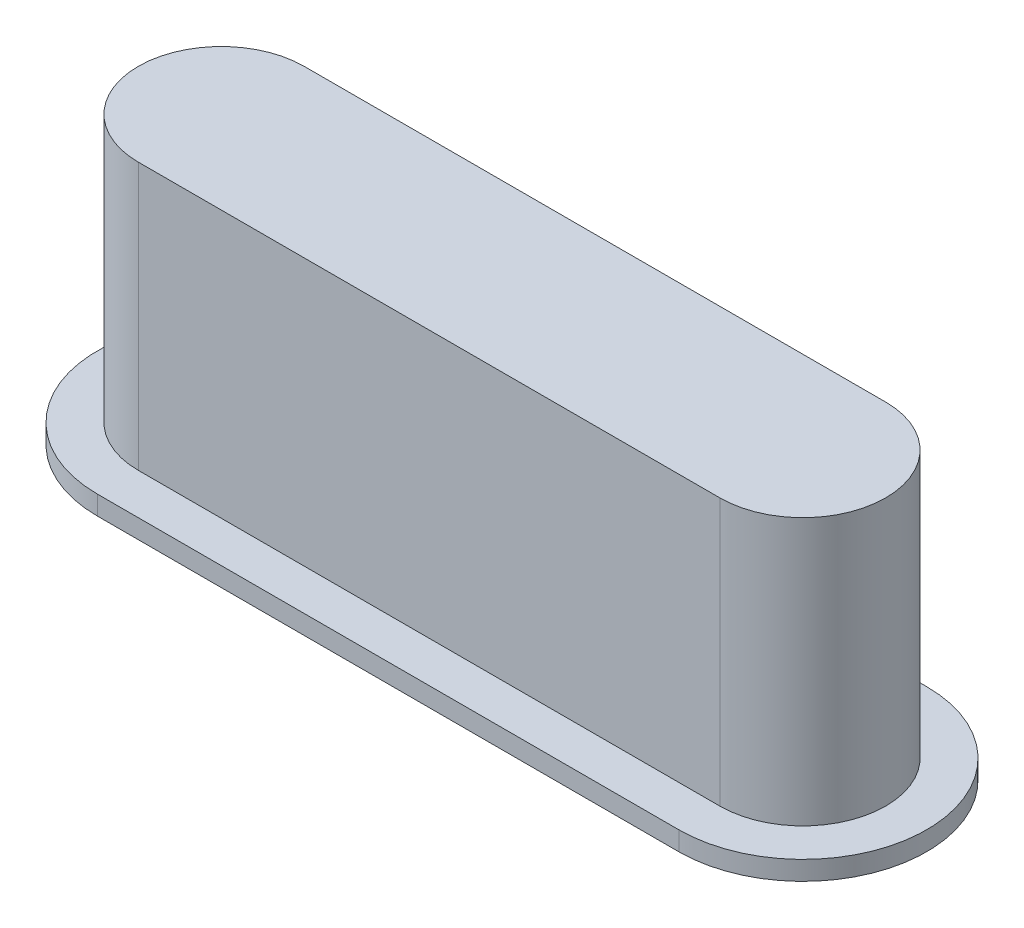
from build123d import *

# Parameters (mm, degrees)
BOSS_EXTRUDE1_DEPTH = 3.556
BOSS_EXTRUDE2_DEPTH = 0.254


with BuildPart() as part:
    # Sketch1 → Boss-Extrude1 (new body)
    with BuildSketch(Plane(origin=(0, 0, 0), x_dir=(1, 0, 0), z_dir=(0, 1, 0))):
        with BuildLine():
            Line((-3.8735, 1.1049), (3.8735, 1.1049))
            ThreePointArc((3.8735, 1.1049), (4.9784, 0), (3.8735, -1.1049))
            Line((3.8735, -1.1049), (-3.8735, -1.1049))
            ThreePointArc((-3.8735, -1.1049), (-4.9784, 0), (-3.8735, 1.1049))
        make_face()
    extrude(amount=BOSS_EXTRUDE1_DEPTH)

    # Sketch3 → Boss-Extrude2 (add)
    with BuildSketch(Plane(origin=(0, 0, 0), x_dir=(1, 0, 0), z_dir=(0, 1, 0))):
        with BuildLine():
            Line((-3.8735, 1.651), (3.8735, 1.651))
            ThreePointArc((3.8735, 1.651), (5.5245, 0), (3.8735, -1.651))
            Line((3.8735, -1.651), (-3.8735, -1.651))
            ThreePointArc((-3.8735, -1.651), (-5.5245, 0), (-3.8735, 1.651))
        make_face()
    extrude(amount=-BOSS_EXTRUDE2_DEPTH)


solid = part.part
